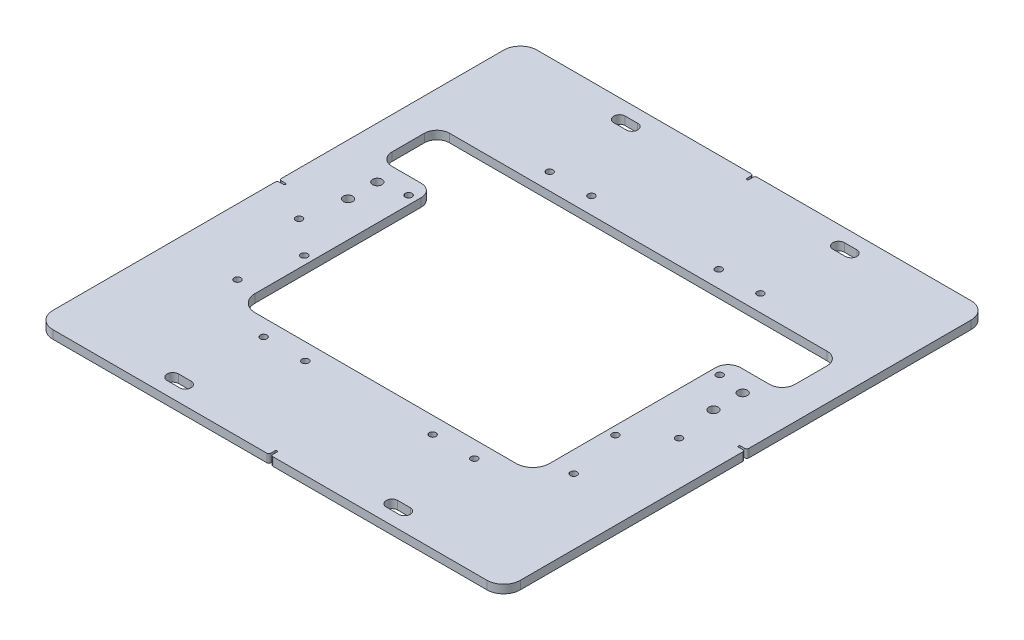
from build123d import *

# Parameters (mm, degrees)
SKETCH2_W               = 355.6
SKETCH2_H               = 368.3
BOSS_EXTRUDE1_DEPTH     = 6.35
FILLET1_R               = 12.7
MOUNTING_HOLES_DEPTH    = 7.35
PLUNGER_CUTOUT_DEPTH    = 7.35
F_1_4_20_TAPPED_HOLE2_D = 5.1054
CENTERING_MARKERS_DEPTH = 7.35
FILLET2_R               = 1.5875
F_1_4_20_TAPPED_HOLE5_D = 5.1054
SKETCH17_R              = 3.571875
CUT_EXTRUDE1_DEPTH      = 7.35


with BuildPart() as part:
    # Sketch2 → Boss-Extrude1 (new body)
    with BuildSketch(Plane(origin=(0, 0, 0), x_dir=(1, 0, 0), z_dir=(0, 1, 0))):
        Rectangle(SKETCH2_W, SKETCH2_H)
    extrude(amount=BOSS_EXTRUDE1_DEPTH)

    # Fillet1
    fillet1_edges = [part.edges().sort_by_distance(p)[0] for p in [
        (177.8, 3.175, 184.15),
        (-177.8, 3.175, 184.15),
        (-177.8, 3.175, -184.15),
        (177.8, 3.175, -184.15),
    ]]
    fillet(fillet1_edges, radius=FILLET1_R)

    # Sketch3 → MOUNTING HOLES (cut, through all)
    with BuildSketch(Plane(origin=(0, 6.35, 0), x_dir=(1, 0, 0), z_dir=(0, 1, 0))):
        with BuildLine():
            Line((-88.10625, 174.228125), (-78.58125, 174.228125))
            ThreePointArc((-78.58125, 174.228125), (-74.215625, 169.8625), (-78.58125, 165.496875))
            Line((-78.58125, 165.496875), (-88.10625, 165.496875))
            ThreePointArc((-88.10625, 165.496875), (-92.471875, 169.8625), (-88.10625, 174.228125))
        make_face()
        with BuildLine():
            Line((88.10625, 165.496875), (78.58125, 165.496875))
            ThreePointArc((78.58125, 165.496875), (74.215625, 169.8625), (78.58125, 174.228125))
            Line((78.58125, 174.228125), (88.10625, 174.228125))
            ThreePointArc((88.10625, 174.228125), (92.471875, 169.8625), (88.10625, 165.496875))
        make_face()
        with BuildLine():
            Line((-88.10625, -165.496875), (-78.58125, -165.496875))
            ThreePointArc((-78.58125, -165.496875), (-74.215625, -169.8625), (-78.58125, -174.228125))
            Line((-78.58125, -174.228125), (-88.10625, -174.228125))
            ThreePointArc((-88.10625, -174.228125), (-92.471875, -169.8625), (-88.10625, -165.496875))
        make_face()
        with BuildLine():
            Line((78.58125, -165.496875), (88.10625, -165.496875))
            ThreePointArc((88.10625, -165.496875), (92.471875, -169.8625), (88.10625, -174.228125))
            Line((88.10625, -174.228125), (78.58125, -174.228125))
            ThreePointArc((78.58125, -174.228125), (74.215625, -169.8625), (78.58125, -165.496875))
        make_face()
    extrude(amount=-MOUNTING_HOLES_DEPTH, mode=Mode.SUBTRACT)

    # Sketch4 → PLUNGER CUTOUT (cut, through all)
    with BuildSketch(Plane(origin=(0, 6.35, 0), x_dir=(1, 0, 0), z_dir=(0, 1, 0))):
        with BuildLine():
            Line((-99.28098, -96.10598), (99.28098, -96.10598))
            ThreePointArc((99.28098, -96.10598), (108.261236121, -92.386236121), (111.98098, -83.40598))
            Line((111.98098, -83.40598), (111.98098, 42.86885))
            ThreePointArc((111.98098, 42.86885), (114.770787909, 49.604042091), (121.50598, 52.39385))
            Line((121.50598, 52.39385), (143.66875, 52.39385))
            ThreePointArc((143.66875, 52.39385), (150.403942091, 55.183657909), (153.19375, 61.91885))
            Line((153.19375, 61.91885), (153.19375, 86.58098))
            ThreePointArc((153.19375, 86.58098), (150.403942091, 93.316172091), (143.66875, 96.10598))
            Line((143.66875, 96.10598), (-143.66875, 96.10598))
            ThreePointArc((-143.66875, 96.10598), (-150.403942091, 93.316172091), (-153.19375, 86.58098))
            Line((-153.19375, 86.58098), (-153.19375, 61.91885))
            ThreePointArc((-153.19375, 61.91885), (-150.403942091, 55.183657909), (-143.66875, 52.39385))
            Line((-143.66875, 52.39385), (-121.50598, 52.39385))
            ThreePointArc((-121.50598, 52.39385), (-114.770787909, 49.604042091), (-111.98098, 42.86885))
            Line((-111.98098, 42.86885), (-111.98098, -83.40598))
            ThreePointArc((-111.98098, -83.40598), (-108.261236121, -92.386236121), (-99.28098, -96.10598))
        make_face()
    extrude(amount=-PLUNGER_CUTOUT_DEPTH, mode=Mode.SUBTRACT)

    # 1/4-20 Tapped Hole2 (through all)
    with Locations(Plane(origin=(0, 6.35, 0), x_dir=(1, 0, 0), z_dir=(0, 1, 0))):
        with Locations((-80.16748, -108.81868), (-48.41748, -108.81868), (48.41748, -108.81868), (80.16748, -108.81868), (80.16748, 108.81868), (48.41748, 108.81868), (-48.41748, 108.81868), (-80.16748, 108.81868)):
            Hole(F_1_4_20_TAPPED_HOLE2_D / 2)

    # Sketch10 → CENTERING MARKERS (cut, through all)
    with BuildSketch(Plane(origin=(0, 6.35, 0), x_dir=(1, 0, 0), z_dir=(0, 1, 0))):
        with BuildLine():
            Line((-0.79375, -179.3875), (-0.79375, -185.007769042))
            Line((-0.79375, -185.007769042), (0.79375, -185.007769042))
            Line((0.79375, -185.007769042), (0.79375, -179.3875))
            ThreePointArc((0.79375, -179.3875), (0, -178.59375), (-0.79375, -179.3875))
        make_face()
        with BuildLine():
            Line((-173.0375, 0.79375), (-178.809191543, 0.79375))
            Line((-178.809191543, 0.79375), (-178.809191543, -0.79375))
            Line((-178.809191543, -0.79375), (-173.0375, -0.79375))
            ThreePointArc((-173.0375, -0.79375), (-172.24375, 0), (-173.0375, 0.79375))
        make_face()
        with BuildLine():
            Line((173.0375, 0.79375), (178.465354943, 0.79375))
            Line((178.465354943, 0.79375), (178.465354943, -0.79375))
            Line((178.465354943, -0.79375), (173.0375, -0.79375))
            ThreePointArc((173.0375, -0.79375), (172.24375, 0), (173.0375, 0.79375))
        make_face()
        with BuildLine():
            Line((-0.79375, 179.3875), (-0.79375, 184.793694415))
            Line((-0.79375, 184.793694415), (0.79375, 184.793694415))
            Line((0.79375, 184.793694415), (0.79375, 179.3875))
            ThreePointArc((0.79375, 179.3875), (0, 178.59375), (-0.79375, 179.3875))
        make_face()
    extrude(amount=-CENTERING_MARKERS_DEPTH, mode=Mode.SUBTRACT)

    # Fillet2
    fillet2_edges = [part.edges().sort_by_distance(p)[0] for p in [
        (177.8, 3.175, -0.79375),
        (177.8, 3.175, 0.79375),
        (0.79375, 3.175, 184.15),
        (-0.79375, 3.175, 184.15),
        (-0.79375, 3.175, -184.15),
        (0.79375, 3.175, -184.15),
        (-177.8, 3.175, 0.79375),
        (-177.8, 3.175, -0.79375),
    ]]
    fillet(fillet2_edges, radius=FILLET2_R)

    # 1/4-20 Tapped Hole5 (through all)
    with Locations(Plane(origin=(0, 6.35, 0), x_dir=(1, 0, 0), z_dir=(0, 1, 0))):
        with Locations((-144.526, -17.4752), (-127.85725, -80.9752), (-118.33225, -39.6875), (-118.33225, 39.6875), (118.33225, 39.6875), (118.33225, -39.6875), (144.526, -17.4752), (127.85725, -80.9752)):
            Hole(F_1_4_20_TAPPED_HOLE5_D / 2)

    # Sketch17 → Cut-Extrude1 (cut, through all)
    with BuildSketch(Plane(origin=(0, 6.35, 0), x_dir=(1, 0, 0), z_dir=(0, 1, 0))):
        with Locations((-138.96975, 36.5125)):
            Circle(SKETCH17_R)
        with Locations((-138.96975, 14.2875)):
            Circle(SKETCH17_R)
        with Locations((138.96975, 14.2875)):
            Circle(SKETCH17_R)
        with Locations((138.96975, 36.5125)):
            Circle(SKETCH17_R)
    extrude(amount=-CUT_EXTRUDE1_DEPTH, mode=Mode.SUBTRACT)


solid = part.part
